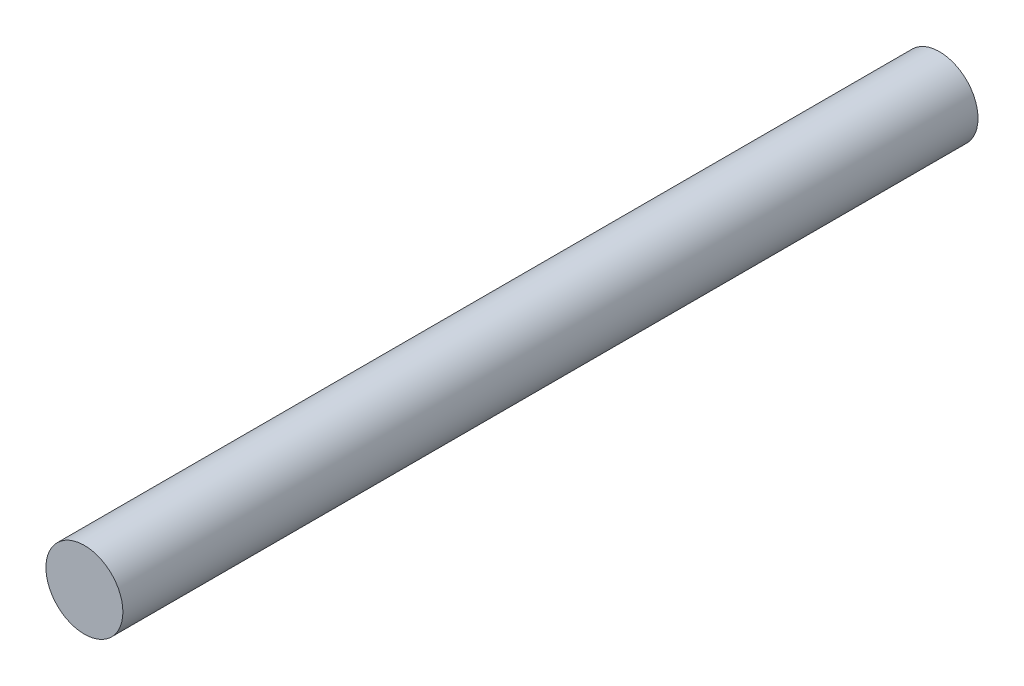
from build123d import *

# Parameters (mm, degrees)
SCHIZZO1_R                   = 1.8
ESTRUSIONE_ESTRUSIONE1_DEPTH = 20


with BuildPart() as part:
    # Schizzo1 → Estrusione-Estrusione1 (new body, symmetric)
    with BuildSketch(Plane.XY):
        Circle(SCHIZZO1_R)
    extrude(amount=ESTRUSIONE_ESTRUSIONE1_DEPTH, both=True)


solid = part.part
